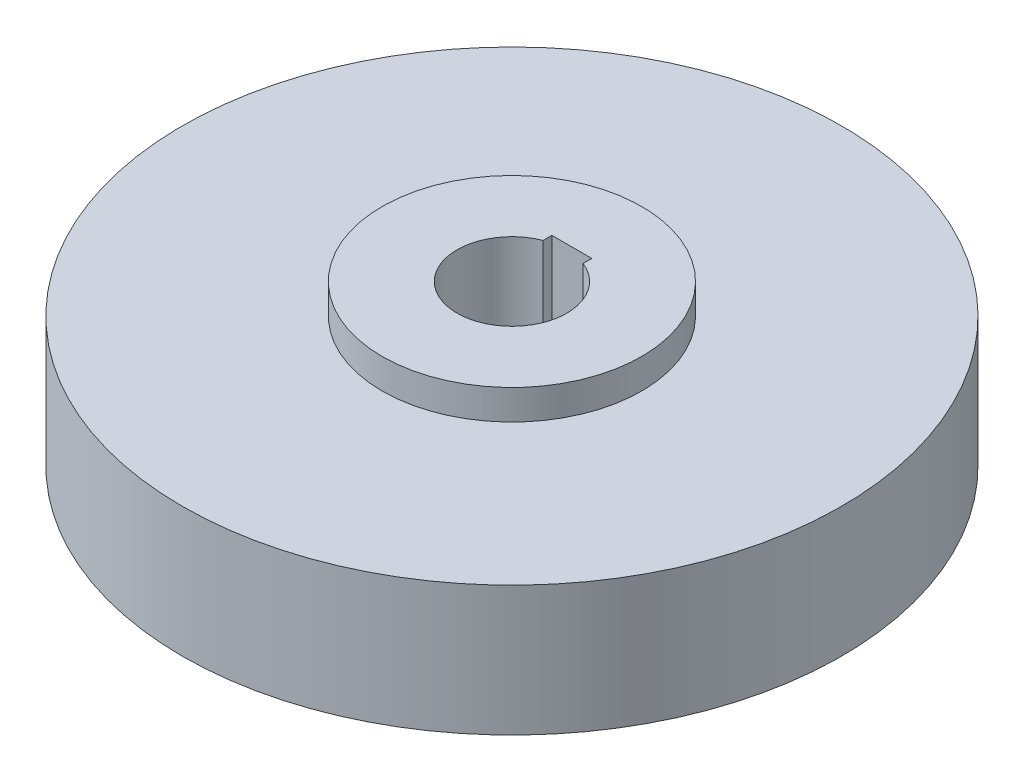
from build123d import *

# Parameters (mm, degrees)
SKETCH1_R               = 33
BOSS_EXTRUDE1_DEPTH     = 13
SKETCH2_R               = 13
BOSS_EXTRUDE2_DEPTH     = 3
CUT_EXTRUDE1_DEPTH      = 1
CUT_EXTRUDE1_DEPTH_BACK = 17


with BuildPart() as part:
    # Sketch1 → Boss-Extrude1 (new body)
    with BuildSketch(Plane(origin=(0, 0, 0), x_dir=(1, 0, 0), z_dir=(0, 1, 0))):
        Circle(SKETCH1_R)
    extrude(amount=BOSS_EXTRUDE1_DEPTH)

    # Sketch2 → Boss-Extrude2 (add)
    with BuildSketch(Plane(origin=(0, 13, 0), x_dir=(1, 0, 0), z_dir=(0, 1, 0))):
        Circle(SKETCH2_R)
    extrude(amount=BOSS_EXTRUDE2_DEPTH)

    # Sketch3 → Cut-Extrude1 (cut, two sides)
    with BuildSketch(Plane(origin=(0, 16, 0), x_dir=(1, 0, 0), z_dir=(0, 1, 0))) as cut_extrude1_sk:
        with BuildLine():
            ThreePointArc((2, 5.123475383), (0, 5.5), (-2, 5.123475383))
            Line((-2, 5.123475383), (-2, 5))
            Line((-2, 5), (2, 5))
            Line((2, 5), (2, 5.123475383))
        make_face()
        with BuildLine():
            Line((-2, 5), (-2, 5.123475383))
            ThreePointArc((-2, 5.123475383), (-3.102418411, -4.541475531), (5.5, 0))
            ThreePointArc((5.5, 0), (4.541475531, 3.102418411), (2, 5.123475383))
            Line((2, 5.123475383), (2, 5))
            Line((2, 5), (-2, 5))
        make_face()
        with BuildLine():
            Line((2, 6), (-2, 6))
            Line((-2, 6), (-2, 5.123475383))
            ThreePointArc((-2, 5.123475383), (0, 5.5), (2, 5.123475383))
            Line((2, 5.123475383), (2, 6))
        make_face()
    extrude(amount=CUT_EXTRUDE1_DEPTH, mode=Mode.SUBTRACT)
    extrude(cut_extrude1_sk.sketch, amount=-CUT_EXTRUDE1_DEPTH_BACK, mode=Mode.SUBTRACT)


solid = part.part
